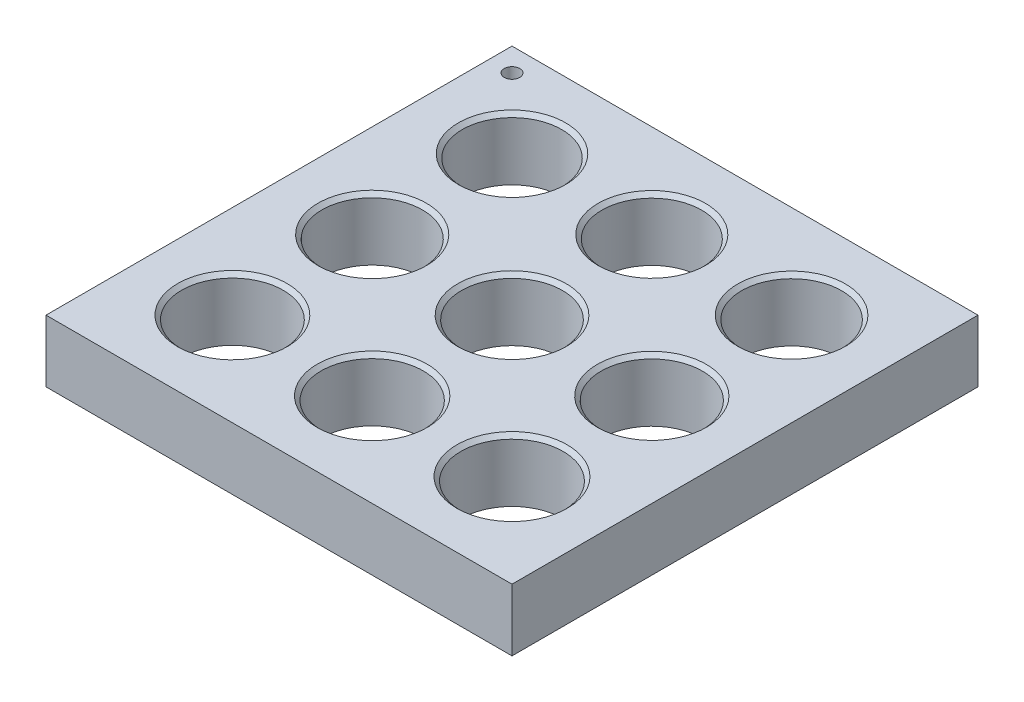
from build123d import *

# Parameters (mm, degrees)
SKETCH1_W               = 60
SKETCH1_H               = 60
BOSS_EXTRUDE1_DEPTH     = 8
SKETCH3_R               = 6.4
SKETCH3_R_2             = 6.425
SKETCH3_R_3             = 6.45
SKETCH3_R_4             = 6.475
SKETCH3_R_5             = 6.5
SKETCH3_R_6             = 6.525
SKETCH3_R_7             = 6.55
SKETCH3_R_8             = 6.575
SKETCH3_R_9             = 6.6
CUT_EXTRUDE1_DEPTH      = 1
CUT_EXTRUDE1_DEPTH_BACK = 9
CHAMFER1_SIZE           = 0.5
SKETCH4_R               = 1
CUT_EXTRUDE2_DEPTH      = 1
CUT_EXTRUDE2_DEPTH_BACK = 2


with BuildPart() as part:
    # Sketch1 → Boss-Extrude1 (new body)
    with BuildSketch(Plane(origin=(0, 0, 0), x_dir=(1, 0, 0), z_dir=(0, 1, 0))):
        Rectangle(SKETCH1_W, SKETCH1_H)
    extrude(amount=BOSS_EXTRUDE1_DEPTH)

    # Sketch3 → Cut-Extrude1 (cut, two sides)
    with BuildSketch(Plane(origin=(0, 8, 0), x_dir=(1, 0, 0), z_dir=(0, 1, 0))) as cut_extrude1_sk:
        with Locations((-18, 18)):
            Circle(SKETCH3_R)
        with Locations((0, 18)):
            Circle(SKETCH3_R_2)
        with Locations((18, 18)):
            Circle(SKETCH3_R_3)
        with Locations((-18, 0)):
            Circle(SKETCH3_R_4)
        Circle(SKETCH3_R_5)
        with Locations((18, 0)):
            Circle(SKETCH3_R_6)
        with Locations((-18, -18)):
            Circle(SKETCH3_R_7)
        with Locations((0, -18)):
            Circle(SKETCH3_R_8)
        with Locations((18, -18)):
            Circle(SKETCH3_R_9)
    extrude(amount=CUT_EXTRUDE1_DEPTH, mode=Mode.SUBTRACT)
    extrude(cut_extrude1_sk.sketch, amount=-CUT_EXTRUDE1_DEPTH_BACK, mode=Mode.SUBTRACT)

    # Chamfer1
    chamfer1_edges = [part.edges().sort_by_distance(p)[0] for p in [
        (-6.425, 8, -18),
        (11.55, 8, -18),
        (-24.475, 8, 0),
        (-6.5, 8, 0),
        (-24.55, 8, 18),
        (11.4, 8, 18),
        (-6.575, 8, 18),
        (11.475, 8, 0),
        (-24.4, 8, -18),
    ]]
    chamfer(chamfer1_edges, length=CHAMFER1_SIZE)

    # Sketch4 → Cut-Extrude2 (cut, two sides)
    with BuildSketch(Plane(origin=(0, 8, 0), x_dir=(1, 0, 0), z_dir=(0, 1, 0))) as cut_extrude2_sk:
        with Locations((-27, 27)):
            Circle(SKETCH4_R)
    extrude(amount=CUT_EXTRUDE2_DEPTH, mode=Mode.SUBTRACT)
    extrude(cut_extrude2_sk.sketch, amount=-CUT_EXTRUDE2_DEPTH_BACK, mode=Mode.SUBTRACT)


solid = part.part
